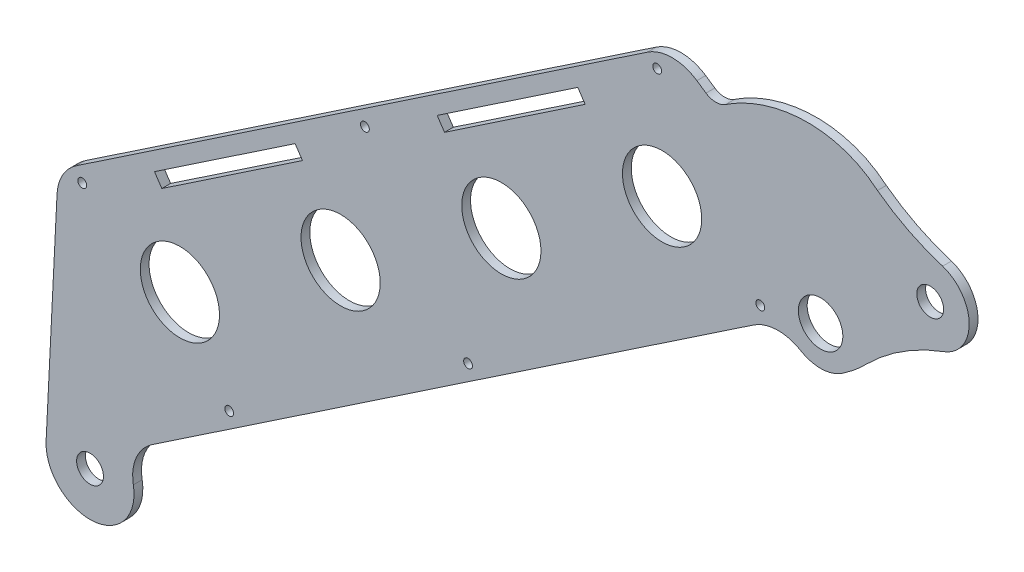
from build123d import *

# Parameters (mm, degrees)
SKETCH_1_R          = 3.05
SKETCH_1_R_2        = 5.05
EXTRUDE_1_DEPTH     = 2
SKETCH_2_R          = 3.05
CUT_EXTRUDE_1_DEPTH = 3.0000001
FILLET_1_R          = 10
FILLET_2_R          = 10
SKETCH_4_R          = 9
CUT_EXTRUDE_3_DEPTH = 10
FILLET_3_R          = 10
SKETCH_5_R          = 1
CUT_EXTRUDE_4_DEPTH = 10
CUT_EXTRUDE_5_DEPTH = 10


with BuildPart() as part:
    # 草图1 → 凸台-拉伸1 (new body)
    with BuildSketch(Plane.XY):
        with BuildLine():
            Line((33.781378488, 60.143481549), (26.111364219, 65.33671315))
            Line((26.111364219, 65.33671315), (-113.414892299, -28.455707895))
            Line((-113.414892299, -28.455707895), (-116.172277489, -83.735077284))
            ThreePointArc((-116.172277489, -83.735077284), (-103.256088302, -93.300423103), (-97.873109363, -78.156205675))
            Line((-97.873109363, -78.156205675), (-98.943047596, -76.564558134))
            Line((-98.943047596, -76.564558134), (51.562392304, 24.608295928))
            ThreePointArc((51.562392304, 24.608295928), (57.170026982, 19.385116489), (64.753479859, 20.488933768))
            add(Edge.make_bspline(
                [(64.753479859, 20.488933768), (66.638530957, 21.755918107), (68.426748806, 23.236531132), (70.062196414, 24.887697208)],
                knots=[0.026108887, 0.026108887, 0.026108887, 0.026108887, 0.973640222, 0.973640222, 0.973640222, 0.973640222], degree=3))
            ThreePointArc((70.062196414, 24.887697208), (78.287330396, 31.54858645), (87.76365302, 36.262351829))
            ThreePointArc((87.76365302, 36.262351829), (93.567944773, 44.696209097), (87.54263496, 52.973611636))
            ThreePointArc((87.54263496, 52.973611636), (79.818181838, 56.073118878), (72.738975332, 60.450213395))
            add(Edge.make_bspline(
                [(72.738975332, 60.450213395), (71.67095149, 61.35223039), (67.696722379, 64.109293298), (55.783849218, 67.566421953), (44.38146919, 64.224123675), (38.244385983, 60.128526636)],
                knots=[0.009949241, 0.009949241, 0.009949241, 0.009949241, 0.121591481, 0.393982167, 0.99006759, 0.99006759, 0.99006759, 0.99006759], degree=3))
            ThreePointArc((38.244385983, 60.128526636), (36.010602622, 59.45569692), (33.781378488, 60.143481549))
        make_face()
        with Locations((-106.172277489, -83.735077284)):
            Circle(SKETCH_1_R, mode=Mode.SUBTRACT)
        with Locations((59.811085021, 27.842354887)):
            Circle(SKETCH_1_R_2, mode=Mode.SUBTRACT)
    extrude(amount=EXTRUDE_1_DEPTH)

    # 草图2 → 切除-拉伸1 (cut, through all)
    with BuildSketch(Plane(origin=(0, 0, 0), x_dir=(-1, 0, 0), z_dir=(0, 0, -1))):
        with Locations((-84.708692938, 44.579039315)):
            Circle(SKETCH_2_R)
    extrude(amount=-CUT_EXTRUDE_1_DEPTH, mode=Mode.SUBTRACT)

    # 圆角1
    fillet_1_edges = [part.edges().sort_by_distance(p)[0] for p in [
        (51.562392304, 24.608295928, 1),
    ]]
    fillet(fillet_1_edges, radius=FILLET_1_R)

    # 圆角2
    fillet_2_edges = [part.edges().sort_by_distance(p)[0] for p in [
        (-113.414892299, -28.455707895, 1),
        (26.111364219, 65.33671315, 1),
    ]]
    fillet(fillet_2_edges, radius=FILLET_2_R)

    # 草图4 → 切除-拉伸3 (cut)
    with BuildSketch(Plane.XY.offset(2)):
        with Locations((-49.240629704, -14.235008927)):
            Circle(SKETCH_4_R)
        with Locations((-12.724289952, 10.312026151)):
            Circle(SKETCH_4_R)
        with Locations((23.792049801, 34.859061229)):
            Circle(SKETCH_4_R)
        with Locations((-85.756969456, -38.782044004)):
            Circle(SKETCH_4_R)
    extrude(amount=-CUT_EXTRUDE_3_DEPTH, mode=Mode.SUBTRACT)

    # 圆角3
    fillet_3_edges = [part.edges().sort_by_distance(p)[0] for p in [
        (-98.943047596, -76.564558134, 1),
    ]]
    fillet(fillet_3_edges, radius=FILLET_3_R)

    # 草图5 → 切除-拉伸4 (cut)
    with BuildSketch(Plane(origin=(0, 0, 0), x_dir=(-1, 0, 0), z_dir=(0, 0, -1))):
        with Locations((-22.674576674, 59.411613704)):
            Circle(SKETCH_5_R)
        with Locations((43.71876833, 14.780640835)):
            Circle(SKETCH_5_R)
        with Locations((107.944085943, -28.392939404)):
            Circle(SKETCH_5_R)
        with Locations((-46.10583743, 24.555107577)):
            Circle(SKETCH_5_R)
        with Locations((20.287507574, -20.075865292)):
            Circle(SKETCH_5_R)
        with Locations((74.553823436, -56.554799601)):
            Circle(SKETCH_5_R)
    extrude(amount=-CUT_EXTRUDE_4_DEPTH, mode=Mode.SUBTRACT)

    # 草图6 → 切除-拉伸5 (cut)
    with BuildSketch(Plane.XY.offset(2)):
        Polygon((4.648732698, 46.691800395), (6.322394181, 44.202049957), (-25.629403102, 22.723394264), (-27.303064585, 25.213144702), align=None)
        Polygon((-89.854720715, -20.450185975), (-57.902923432, 1.028469718), (-59.576584915, 3.518220156), (-91.528382198, -17.960435537), align=None)
    extrude(amount=-CUT_EXTRUDE_5_DEPTH, mode=Mode.SUBTRACT)


solid = part.part
